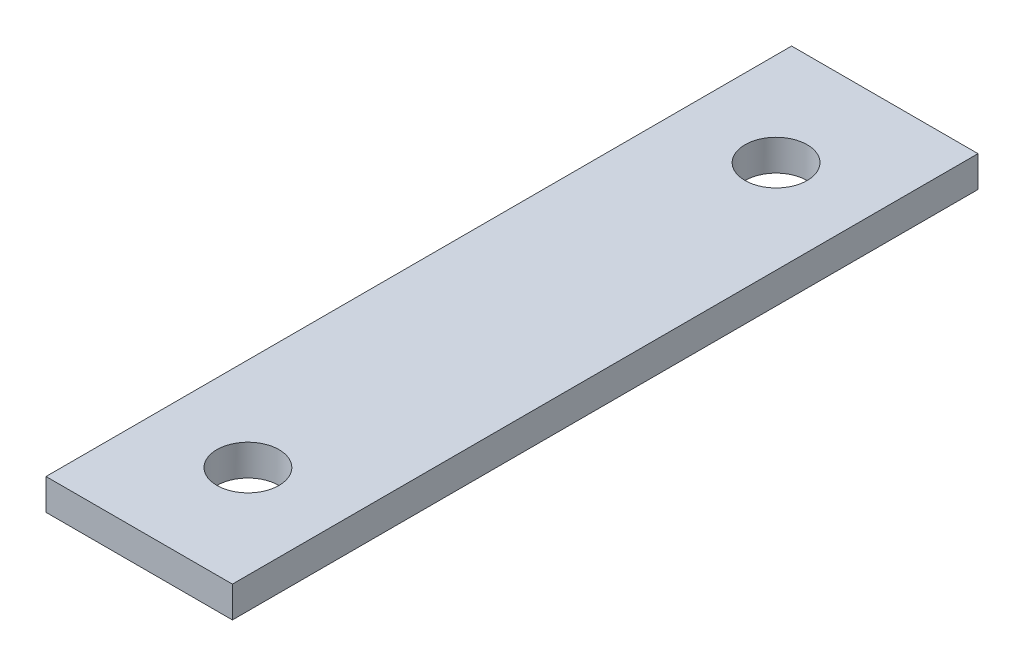
from build123d import *

# Parameters (mm, degrees)
SKETCH1_W           = 3
SKETCH1_H           = 12
BOSS_EXTRUDE1_DEPTH = 0.5
SKETCH2_R           = 0.5
CUT_EXTRUDE1_DEPTH  = 1


with BuildPart() as part:
    # Sketch1 → Boss-Extrude1 (new body)
    with BuildSketch(Plane(origin=(0, 0, 0), x_dir=(1, 0, 0), z_dir=(0, 1, 0))):
        with Locations((0, 2.768181818)):
            Rectangle(SKETCH1_W, SKETCH1_H)
    extrude(amount=BOSS_EXTRUDE1_DEPTH)

    # Sketch2 → Cut-Extrude1 (cut)
    with BuildSketch(Plane(origin=(0, 0.5, 0), x_dir=(1, 0, 0), z_dir=(0, 1, 0))):
        with Locations((0, 7.018181818)):
            Circle(SKETCH2_R)
        with Locations((0, -1.481818182)):
            Circle(SKETCH2_R)
    extrude(amount=-CUT_EXTRUDE1_DEPTH, mode=Mode.SUBTRACT)


solid = part.part
